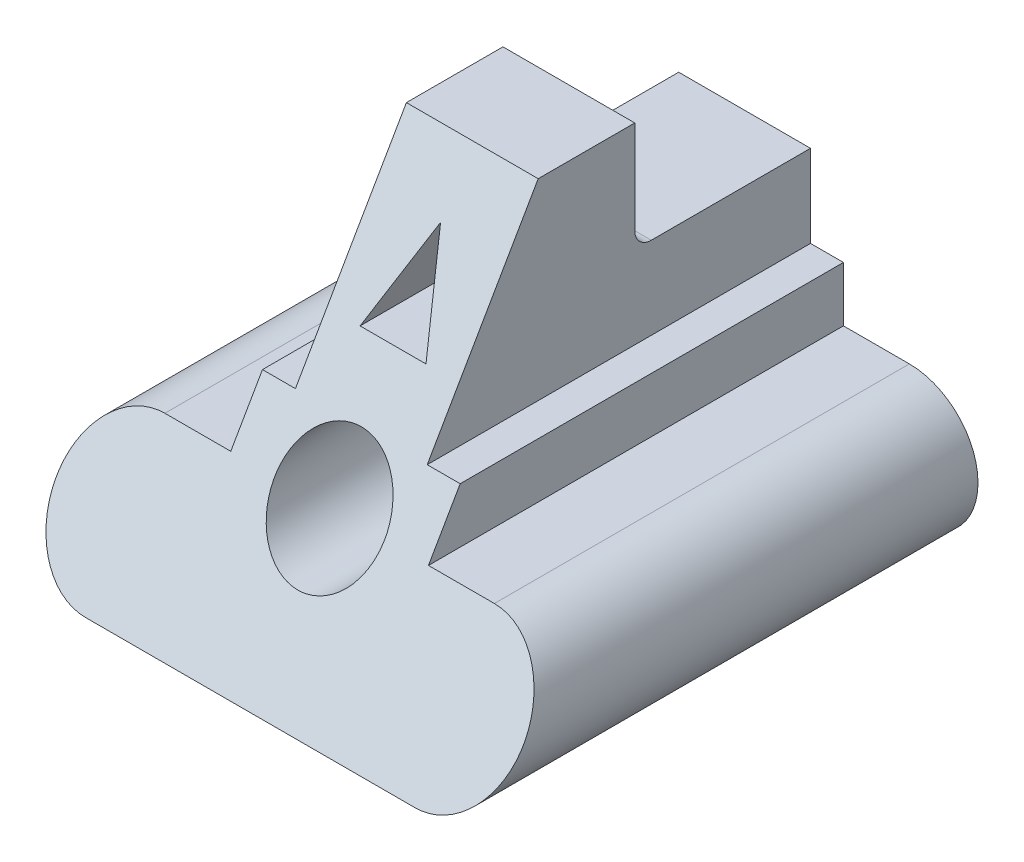
from build123d import *

# Parameters (mm, degrees)
SKETCH1_R           = 10
BOSS_EXTRUDE1_DEPTH = 90
SKETCH2_W           = 32
SKETCH2_H           = 20
CUT_EXTRUDE1_DEPTH  = 30
FILLET1_R           = 3
CUT_EXTRUDE2_DEPTH  = 55
SKETCH6_W           = 93.565518088
SKETCH6_H           = 91.977475816
CUT_EXTRUDE3_DEPTH  = 55


with BuildPart() as part:
    # Sketch1 → Boss-Extrude1 (new body)
    with BuildSketch(Plane.XY):
        with BuildLine():
            Line((-30, 12.5), (-18, 12.5))
            Line((-18, 12.5), (-18, 22.5))
            Line((-18, 22.5), (-12, 22.5))
            Line((-12, 22.5), (-12, 57.5))
            Line((-12, 57.5), (12, 57.5))
            Line((12, 57.5), (12, 22.5))
            Line((12, 22.5), (18, 22.5))
            Line((18, 22.5), (18, 12.5))
            Line((18, 12.5), (30, 12.5))
            ThreePointArc((30, 12.5), (42.5, 0), (30, -12.5))
            Line((30, -12.5), (-30, -12.5))
            ThreePointArc((-30, -12.5), (-42.5, 0), (-30, 12.5))
        make_face()
        with Locations((0, 12.5)):
            Circle(SKETCH1_R, mode=Mode.SUBTRACT)
    extrude(amount=-BOSS_EXTRUDE1_DEPTH)

    # Sketch2 → Cut-Extrude1 (cut)
    with BuildSketch(Plane(origin=(12, 0, 0), x_dir=(0, 0, -1), z_dir=(1, 0, 0))):
        with Locations((74, 47.5)):
            Rectangle(SKETCH2_W, SKETCH2_H)
    extrude(amount=-CUT_EXTRUDE1_DEPTH, mode=Mode.SUBTRACT)

    # Fillet1
    fillet1_edges = [part.edges().sort_by_distance(p)[0] for p in [
        (0, 37.5, -58),
    ]]
    fillet(fillet1_edges, radius=FILLET1_R)

    # Sketch3 → Cut-Extrude2 (cut)
    with BuildSketch(Plane.XY):
        Polygon((0, 47.5), (-6, 32.5), (6, 32.5), align=None)
    extrude(amount=-CUT_EXTRUDE2_DEPTH, mode=Mode.SUBTRACT)

    # Sketch6 → Cut-Extrude3 (cut)
    with BuildSketch(Plane(origin=(0, -3.125, -5.412658774), x_dir=(1, 0, 0), z_dir=(0, 0.5, 0.866025404))):
        with Locations((1.570824933, 32.896964302)):
            Rectangle(SKETCH6_W, SKETCH6_H)
    extrude(amount=CUT_EXTRUDE3_DEPTH, mode=Mode.SUBTRACT)


solid = part.part
